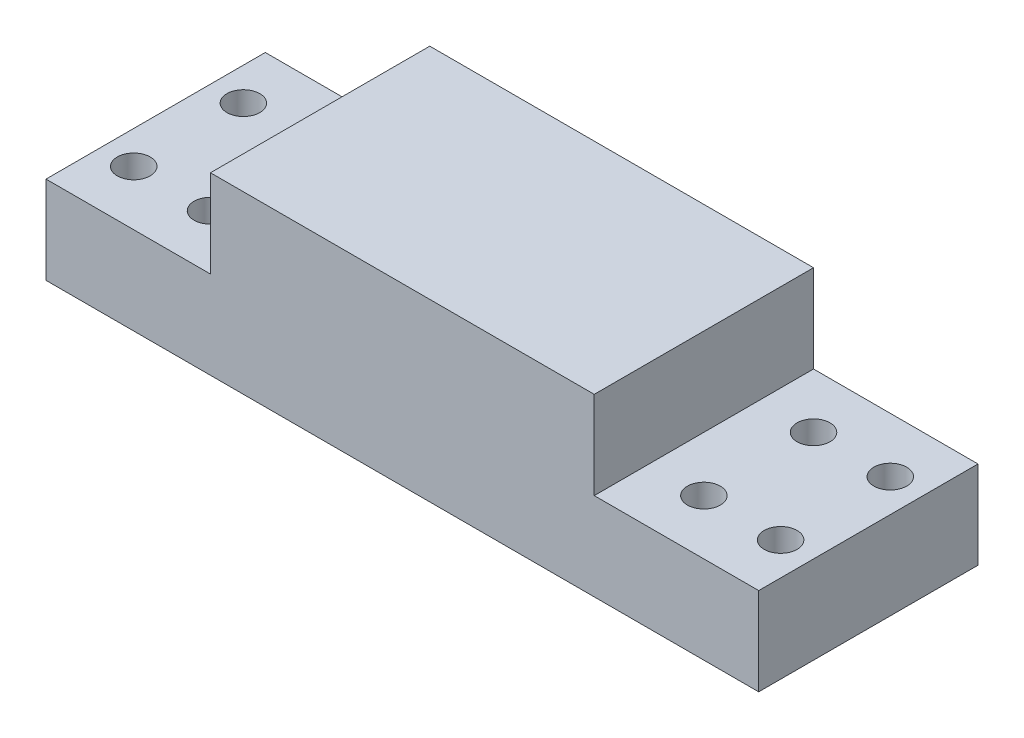
from build123d import *

# Parameters (mm, degrees)
SKETCH1_R             = 1.5
BOSS_EXTRUDE3_DEPTH   = 8
BOSS_EXTRUDE3_2_DEPTH = 8
SKETCH4_W             = 35
SKETCH4_H             = 20
BOSS_EXTRUDE4_DEPTH   = 16


with BuildPart() as part:
    # Sketch1 → Boss-Extrude3 (new body)
    with BuildSketch(Plane(origin=(0, 0, 0), x_dir=(1, 0, 0), z_dir=(0, 1, 0))):
        Polygon((32.5, -10), (32.5, 10), (17.5, 10), (17.5, 5), (17.5, -5), (17.5, -10), align=None)
        with BuildLine():
            ThreePointArc((24, -5), (22.5, -6.5), (21, -5))
            ThreePointArc((21, -5), (22.5, -3.5), (24, -5))
        make_face(mode=Mode.SUBTRACT)
        with Locations((29.5, -5)):
            Circle(SKETCH1_R, mode=Mode.SUBTRACT)
        with BuildLine():
            ThreePointArc((24, 5), (22.5, 3.5), (21, 5))
            ThreePointArc((21, 5), (22.5, 6.5), (24, 5))
        make_face(mode=Mode.SUBTRACT)
        with Locations((29.5, 5)):
            Circle(SKETCH1_R, mode=Mode.SUBTRACT)
    extrude(amount=BOSS_EXTRUDE3_DEPTH)



with BuildPart() as body_2:
    # Sketch1 → Boss-Extrude3 2 (new body)
    with BuildSketch(Plane(origin=(0, 0, 0), x_dir=(1, 0, 0), z_dir=(0, 1, 0))):
        Polygon((-17.5, 5), (-17.5, 10), (-32.5, 10), (-32.5, -10), (-17.5, -10), align=None)
        with BuildLine():
            ThreePointArc((-28, -5), (-30.560660172, -6.060660172), (-29.5, -3.5))
            ThreePointArc((-29.5, -3.5), (-28.439339828, -3.939339828), (-28, -5))
        make_face(mode=Mode.SUBTRACT)
        with Locations((-22.5, -5)):
            Circle(SKETCH1_R, mode=Mode.SUBTRACT)
        with BuildLine():
            ThreePointArc((-29.5, 3.5), (-30.560660172, 6.060660172), (-28, 5))
            ThreePointArc((-28, 5), (-28.439339828, 3.939339828), (-29.5, 3.5))
        make_face(mode=Mode.SUBTRACT)
        with BuildLine():
            ThreePointArc((-24, 5), (-22.5, 6.5), (-21, 5))
            ThreePointArc((-21, 5), (-22.5, 3.5), (-24, 5))
        make_face(mode=Mode.SUBTRACT)
    extrude(amount=BOSS_EXTRUDE3_2_DEPTH)


with BuildPart() as part_1:
    add(part.part)

    add(body_2.part)  # Boss-Extrude4 merges body 2
    # Sketch4 → Boss-Extrude4 (add)
    with BuildSketch(Plane.XZ):
        Rectangle(SKETCH4_W, SKETCH4_H)
    extrude(amount=-BOSS_EXTRUDE4_DEPTH)


solid = part_1.part
